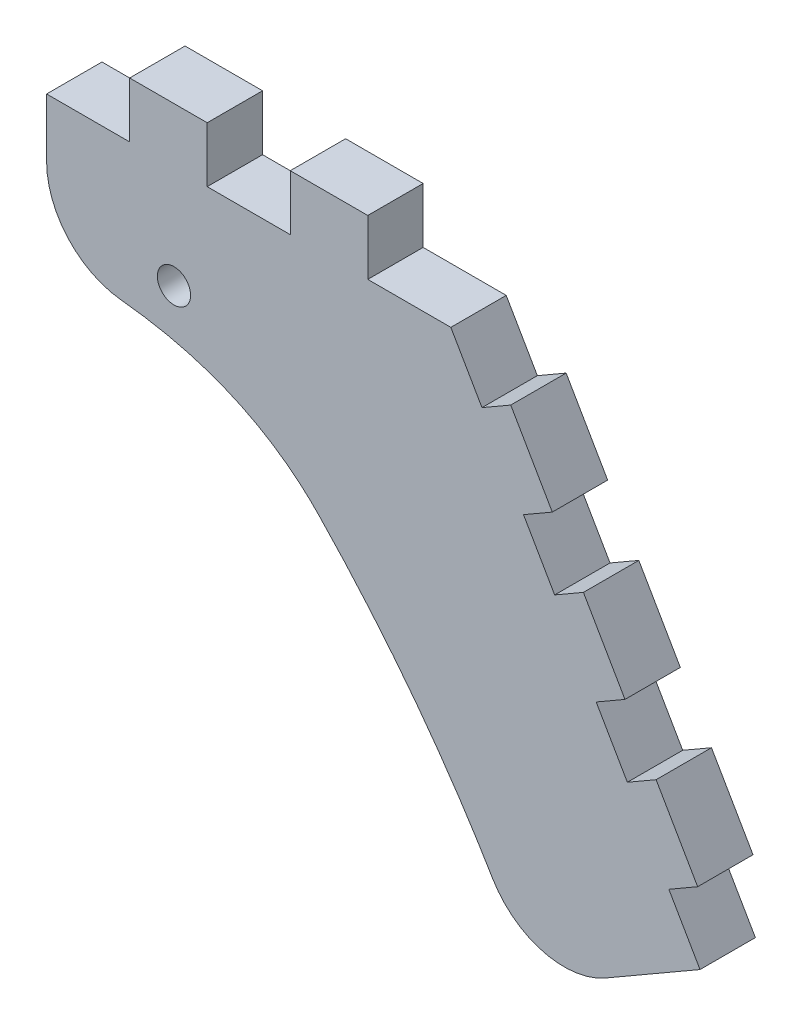
from build123d import *

# Parameters (mm, degrees)
SKETCH1_R           = 3
BOSS_EXTRUDE1_DEPTH = 10
FILLET1_R           = 15


with BuildPart() as part:
    # Sketch1 → Boss-Extrude1 (new body)
    with BuildSketch(Plane.XY):
        with BuildLine():
            Line((0, 0), (15, 0))
            Line((15, 0), (15, 10))
            Line((15, 10), (29, 10))
            Line((29, 10), (29, 0))
            Line((29, 0), (44, 0))
            Line((44, 0), (44, 10))
            Line((44, 10), (58, 10))
            Line((58, 10), (58, 0))
            Line((58, 0), (73, 0))
            Line((73, 0), (78.625, -9.742785793))
            Line((78.625, -9.742785793), (83.821152423, -6.742785793))
            Line((83.821152423, -6.742785793), (91.321152423, -19.733166849))
            Line((91.321152423, -19.733166849), (86.125, -22.733166849))
            Line((86.125, -22.733166849), (91.75, -32.475952642))
            Line((91.75, -32.475952642), (96.946152423, -29.475952642))
            Line((96.946152423, -29.475952642), (104.446152423, -42.466333699))
            Line((104.446152423, -42.466333699), (99.25, -45.466333699))
            Line((99.25, -45.466333699), (104.875, -55.209119491))
            Line((104.875, -55.209119491), (110.071152423, -52.209119491))
            Line((110.071152423, -52.209119491), (117.571152423, -65.199500548))
            Line((117.571152423, -65.199500548), (112.375, -68.199500548))
            Line((112.375, -68.199500548), (118, -77.942286341))
            Line((118, -77.942286341), (87.689110868, -95.442286341))
            add(Edge.make_bspline(
                [(87.689110868, -95.442286341), (77.660181341, -75.620017272), (64.817303381, -57.569676854), (49.160476986, -41.291265088)],
                knots=[0, 0, 0, 0, 1, 1, 1, 1], degree=3))
            add(Edge.make_bspline(
                [(0, -25), (17.242534467, -24.639573707), (35.899987596, -27.504326339), (49.160476986, -41.291265088)],
                knots=[0, 0, 0, 0, 1, 1, 1, 1], degree=3))
            Line((0, -25), (0, 0))
        make_face()
        with Locations((23, -18.5)):
            Circle(SKETCH1_R, mode=Mode.SUBTRACT)
    extrude(amount=BOSS_EXTRUDE1_DEPTH)

    # Fillet1
    fillet1_edges = [part.edges().sort_by_distance(p)[0] for p in [
        (87.689110868, -95.442286341, 5),
        (0, -25, 5),
    ]]
    fillet(fillet1_edges, radius=FILLET1_R)


solid = part.part
